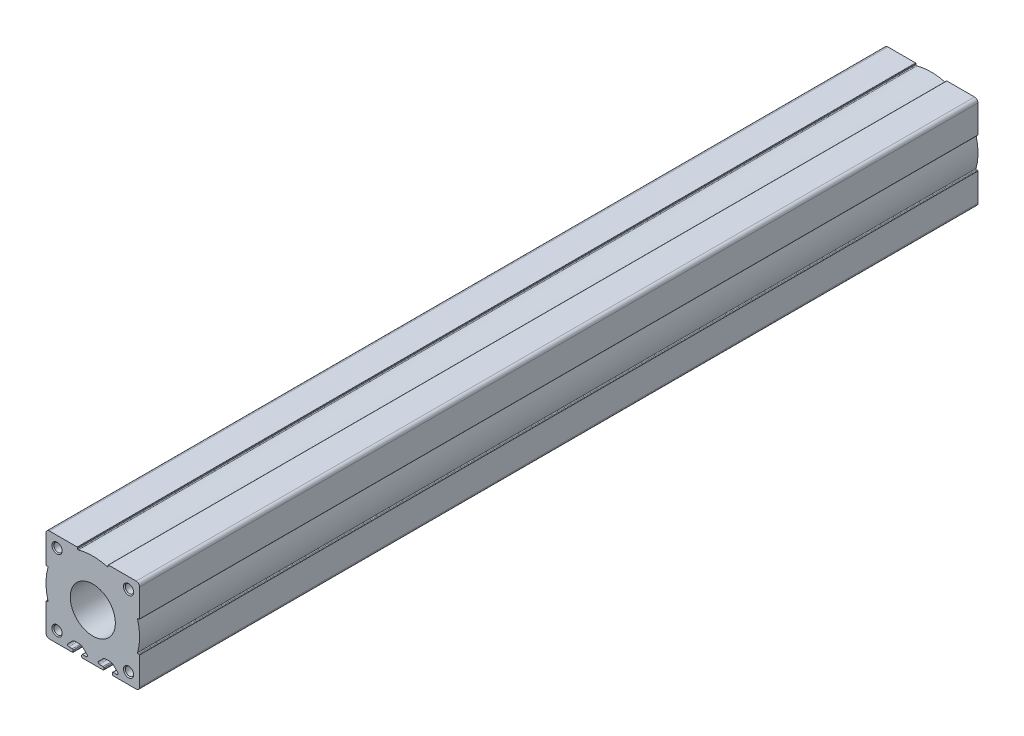
from build123d import *

# Parameters (mm, degrees)
BOSS_EXTRUDE1_DEPTH = 492.7
SKETCH2_W           = 110
SKETCH2_H           = 110
CUT_EXTRUDE1_DEPTH  = 492.7


with BuildPart() as part:
    # Sketch1 → Boss-Extrude1 (new body)
    with BuildSketch(Plane.XY):
        with BuildLine():
            Line((-25.5, -27.5), (25.5, -27.5))
            ThreePointArc((25.5, -27.5), (26.914213562, -26.914213562), (27.5, -25.5))
            Line((27.5, -25.5), (27.5, 25.5))
            ThreePointArc((27.5, 25.5), (26.914213562, 26.914213562), (25.5, 27.5))
            Line((25.5, 27.5), (-25.5, 27.5))
            ThreePointArc((-25.5, 27.5), (-26.914213562, 26.914213562), (-27.5, 25.5))
            Line((-27.5, 25.5), (-27.5, -25.5))
            ThreePointArc((-27.5, -25.5), (-26.914213562, -26.914213562), (-25.5, -27.5))
        make_face()
    extrude(amount=-BOSS_EXTRUDE1_DEPTH)

    # Sketch2 → Cut-Extrude1 (cut)
    with BuildSketch(Plane.XY):
        Rectangle(SKETCH2_W, SKETCH2_H)
        with BuildLine():
            Line((-26.699337741, -9), (-27.3, -9))
            ThreePointArc((-27.3, -9), (-27.441421356, -9.058578644), (-27.5, -9.2))
            Line((-27.5, -9.2), (-27.5, -25.5))
            ThreePointArc((-27.5, -25.5), (-26.914213562, -26.914213562), (-25.5, -27.5))
            Line((-25.5, -27.5), (-11.75, -27.5))
            Line((-11.75, -27.5), (-11.646446609, -27.396446609))
            ThreePointArc((-11.646446609, -27.396446609), (-11.538060234, -27.234234935), (-11.5, -27.042893219))
            Line((-11.5, -27.042893219), (-11.5, -26.2))
            ThreePointArc((-11.5, -26.2), (-11.646446609, -25.846446609), (-12, -25.7))
            Line((-12, -25.7), (-14.089339828, -25.7))
            ThreePointArc((-14.089339828, -25.7), (-14.782249478, -25.237012574), (-14.619669914, -24.419669914))
            Line((-14.619669914, -24.419669914), (-12.178679656, -21.978679656))
            ThreePointArc((-12.178679656, -21.978679656), (-11.20540961, -21.328361402), (-10.057359313, -21.1))
            Line((-10.057359313, -21.1), (-7.942640687, -21.1))
            ThreePointArc((-7.942640687, -21.1), (-6.79459039, -21.328361402), (-5.821320344, -21.978679656))
            Line((-5.821320344, -21.978679656), (-3.380330086, -24.419669914))
            ThreePointArc((-3.380330086, -24.419669914), (-3.217750522, -25.237012574), (-3.910660172, -25.7))
            Line((-3.910660172, -25.7), (-6, -25.7))
            ThreePointArc((-6, -25.7), (-6.353553391, -25.846446609), (-6.5, -26.2))
            Line((-6.5, -26.2), (-6.5, -27.042893219))
            ThreePointArc((-6.5, -27.042893219), (-6.461939766, -27.234234935), (-6.353553391, -27.396446609))
            Line((-6.353553391, -27.396446609), (-6.25, -27.5))
            Line((-6.25, -27.5), (6.25, -27.5))
            Line((6.25, -27.5), (6.353553391, -27.396446609))
            ThreePointArc((6.353553391, -27.396446609), (6.461939766, -27.234234935), (6.5, -27.042893219))
            Line((6.5, -27.042893219), (6.5, -26.2))
            ThreePointArc((6.5, -26.2), (6.353553391, -25.846446609), (6, -25.7))
            Line((6, -25.7), (3.910660172, -25.7))
            ThreePointArc((3.910660172, -25.7), (3.217750522, -25.237012574), (3.380330086, -24.419669914))
            Line((3.380330086, -24.419669914), (5.821320344, -21.978679656))
            ThreePointArc((5.821320344, -21.978679656), (6.79459039, -21.328361402), (7.942640687, -21.1))
            Line((7.942640687, -21.1), (10.057359313, -21.1))
            ThreePointArc((10.057359313, -21.1), (11.20540961, -21.328361402), (12.178679656, -21.978679656))
            Line((12.178679656, -21.978679656), (14.619669914, -24.419669914))
            ThreePointArc((14.619669914, -24.419669914), (14.782249478, -25.237012574), (14.089339828, -25.7))
            Line((14.089339828, -25.7), (12, -25.7))
            ThreePointArc((12, -25.7), (11.646446609, -25.846446609), (11.5, -26.2))
            Line((11.5, -26.2), (11.5, -27.042893219))
            ThreePointArc((11.5, -27.042893219), (11.538060234, -27.234234935), (11.646446609, -27.396446609))
            Line((11.646446609, -27.396446609), (11.75, -27.5))
            Line((11.75, -27.5), (25.5, -27.5))
            ThreePointArc((25.5, -27.5), (26.914213562, -26.914213562), (27.5, -25.5))
            Line((27.5, -25.5), (27.5, -9.2))
            ThreePointArc((27.5, -9.2), (27.441421356, -9.058578644), (27.3, -9))
            Line((27.3, -9), (26.699337741, -9))
            ThreePointArc((26.699337741, -9), (26.380102987, -8.841016954), (26.314632802, -8.49044586))
            ThreePointArc((26.314632802, -8.49044586), (27.5, 0), (26.314632802, 8.49044586))
            ThreePointArc((26.314632802, 8.49044586), (26.380102987, 8.841016954), (26.699337741, 9))
            Line((26.699337741, 9), (27.3, 9))
            ThreePointArc((27.3, 9), (27.441421356, 9.058578644), (27.5, 9.2))
            Line((27.5, 9.2), (27.5, 25.5))
            ThreePointArc((27.5, 25.5), (26.914213562, 26.914213562), (25.5, 27.5))
            Line((25.5, 27.5), (9.2, 27.5))
            ThreePointArc((9.2, 27.5), (9.058578644, 27.441421356), (9, 27.3))
            Line((9, 27.3), (9, 26.699337741))
            ThreePointArc((9, 26.699337741), (8.841016954, 26.380102987), (8.49044586, 26.314632802))
            ThreePointArc((8.49044586, 26.314632802), (0, 27.5), (-8.49044586, 26.314632802))
            ThreePointArc((-8.49044586, 26.314632802), (-8.841016954, 26.380102987), (-9, 26.699337741))
            Line((-9, 26.699337741), (-9, 27.3))
            ThreePointArc((-9, 27.3), (-9.058578644, 27.441421356), (-9.2, 27.5))
            Line((-9.2, 27.5), (-25.5, 27.5))
            ThreePointArc((-25.5, 27.5), (-26.914213562, 26.914213562), (-27.5, 25.5))
            Line((-27.5, 25.5), (-27.5, 9.2))
            ThreePointArc((-27.5, 9.2), (-27.441421356, 9.058578644), (-27.3, 9))
            Line((-27.3, 9), (-26.699337741, 9))
            ThreePointArc((-26.699337741, 9), (-26.380102987, 8.841016954), (-26.314632802, 8.49044586))
            ThreePointArc((-26.314632802, 8.49044586), (-27.5, 0), (-26.314632802, -8.49044586))
            ThreePointArc((-26.314632802, -8.49044586), (-26.380102987, -8.841016954), (-26.699337741, -9))
        make_face(mode=Mode.SUBTRACT)
    extrude(amount=-CUT_EXTRUDE1_DEPTH, mode=Mode.SUBTRACT)

    # Sketch3 → Cut-Revolve1 (revolve, cut)
    with BuildSketch(Plane(origin=(0, 0, 0), x_dir=(0, 0, -1), z_dir=(1, 0, 0))):
        Polygon((478.5, 0), (478.5, 3.175), (488.5, 3.175), (488.5, 9.8), (488.3, 10), (478.5, 10), (478.5, 14), (490.2, 14), (490.2, 19.0625), (492.7, 19.0625), (492.7, 0), align=None)
    revolve(axis=Axis((0, 0, -492.7), (0, 0, 1)), mode=Mode.SUBTRACT)

    # Sketch4 → Cut-Revolve2 (revolve, cut)
    with BuildSketch(Plane(origin=(0, 0, 0), x_dir=(0, 0, -1), z_dir=(1, 0, 0))):
        Polygon((-21.5, 0), (-21.5, 13.26), (105, 13.26), (105, 20), (415, 20), (415, 0), align=None)
    revolve(axis=Axis((0, 0, -415), (0, 0, 1)), mode=Mode.SUBTRACT)

    # Sketch5 → Cut-Revolve3 (revolve, cut)
    with BuildSketch(Plane(origin=(21, 0, 0), x_dir=(0, 0, -1), z_dir=(1, 0, 0))):
        Polygon((0, 21), (0, 24), (0.5415, 23.4585), (16, 23.4585), (17.419415637, 21), align=None)
    revolve(axis=Axis((21, 21, -17.419415637), (0, 0, 1)), mode=Mode.SUBTRACT)

    # Sketch6 → Cut-Revolve4 (revolve, cut)
    with BuildSketch(Plane(origin=(21, 0, 0), x_dir=(0, 0, -1), z_dir=(1, 0, 0))):
        Polygon((0, -21), (0, -18), (0.5415, -18.5415), (16, -18.5415), (17.419415637, -21), align=None)
    revolve(axis=Axis((21, -21, -17.419415637), (0, 0, 1)), mode=Mode.SUBTRACT)

    # Sketch7 → Cut-Revolve5 (revolve, cut)
    with BuildSketch(Plane(origin=(-21, 0, 0), x_dir=(0, 0, -1), z_dir=(1, 0, 0))):
        Polygon((0, 21), (0, 24), (0.5415, 23.4585), (16, 23.4585), (17.419415637, 21), align=None)
    revolve(axis=Axis((-21, 21, -17.419415637), (0, 0, 1)), mode=Mode.SUBTRACT)

    # Sketch8 → Cut-Revolve6 (revolve, cut)
    with BuildSketch(Plane(origin=(-21, 0, 0), x_dir=(0, 0, -1), z_dir=(1, 0, 0))):
        Polygon((0, -21), (0, -18), (0.5415, -18.5415), (16, -18.5415), (17.419415637, -21), align=None)
    revolve(axis=Axis((-21, -21, -17.419415637), (0, 0, 1)), mode=Mode.SUBTRACT)

    # Sketch9 → Cut-Revolve7 (revolve, cut)
    with BuildSketch(Plane(origin=(-23.57, 0, 0), x_dir=(0, 0, -1), z_dir=(1, 0, 0))):
        Polygon((476.506616994, 23.57), (477.7, 25.637), (492.267, 25.637), (492.7, 26.07), (492.7, 23.57), align=None)
    revolve(axis=Axis((-23.57, 23.57, -492.7), (0, 0, 1)), mode=Mode.SUBTRACT)

    # Sketch10 → Cut-Revolve8 (revolve, cut)
    with BuildSketch(Plane(origin=(-23.57, 0, 0), x_dir=(0, 0, -1), z_dir=(1, 0, 0))):
        Polygon((476.506616994, -23.57), (477.7, -21.503), (492.267, -21.503), (492.7, -21.07), (492.7, -23.57), align=None)
    revolve(axis=Axis((-23.57, -23.57, -492.7), (0, 0, 1)), mode=Mode.SUBTRACT)

    # Sketch11 → Cut-Revolve9 (revolve, cut)
    with BuildSketch(Plane(origin=(23.57, 0, 0), x_dir=(0, 0, -1), z_dir=(1, 0, 0))):
        Polygon((476.506616994, 23.57), (477.7, 25.637), (492.267, 25.637), (492.7, 26.07), (492.7, 23.57), align=None)
    revolve(axis=Axis((23.57, 23.57, -492.7), (0, 0, 1)), mode=Mode.SUBTRACT)

    # Sketch12 → Cut-Revolve10 (revolve, cut)
    with BuildSketch(Plane(origin=(23.57, 0, 0), x_dir=(0, 0, -1), z_dir=(1, 0, 0))):
        Polygon((476.506616994, -23.57), (477.7, -21.503), (492.267, -21.503), (492.7, -21.07), (492.7, -23.57), align=None)
    revolve(axis=Axis((23.57, -23.57, -492.7), (0, 0, 1)), mode=Mode.SUBTRACT)


solid = part.part
